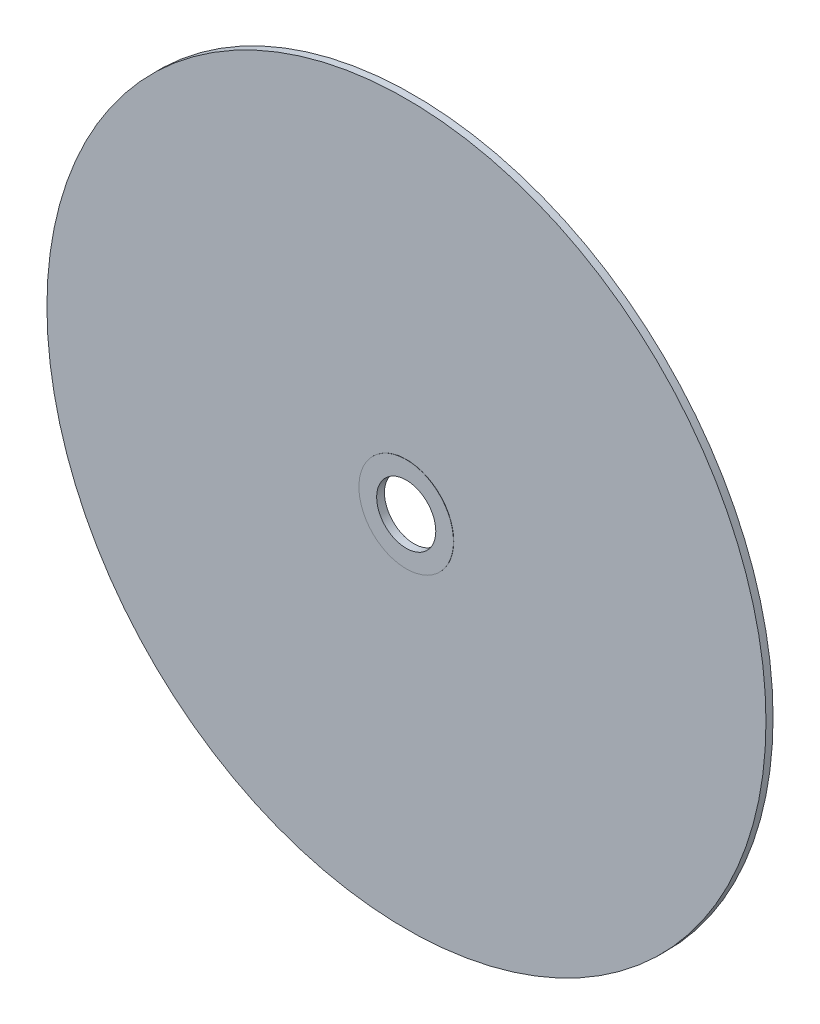
from build123d import *

# Parameters (mm, degrees)
SKETCH1_R                = 152
BOSS_EXTRUDE1_DEPTH      = 3
SKETCH2_R                = 12.5
CUT_EXTRUDE1_DEPTH       = 3
SKETCH3_R                = 20
BOSS_EXTRUDE2_DEPTH      = 0.1
BOSS_EXTRUDE2_DEPTH_BACK = 3.2
SKETCH4_R                = 12.5
CUT_EXTRUDE2_DEPTH       = 50.1


with BuildPart() as part:
    # Sketch1 → Boss-Extrude1 (new body)
    with BuildSketch(Plane.XY):
        Circle(SKETCH1_R)
    extrude(amount=BOSS_EXTRUDE1_DEPTH)

    # Sketch2 → Cut-Extrude1 (cut)
    with BuildSketch(Plane.XY.offset(3)):
        Circle(SKETCH2_R)
    extrude(amount=-CUT_EXTRUDE1_DEPTH, mode=Mode.SUBTRACT)

    # Sketch3 → Boss-Extrude2 (add, two sides)
    with BuildSketch(Plane.XY.offset(3)) as boss_extrude2_sk:
        Circle(SKETCH3_R)
    extrude(amount=BOSS_EXTRUDE2_DEPTH)
    extrude(boss_extrude2_sk.sketch, amount=-BOSS_EXTRUDE2_DEPTH_BACK)

    # Sketch4 → Cut-Extrude2 (cut)
    with BuildSketch(Plane(origin=(0, 0, -0.2), x_dir=(-1, 0, 0), z_dir=(0, 0, -1))):
        Circle(SKETCH4_R)
    extrude(amount=-CUT_EXTRUDE2_DEPTH, mode=Mode.SUBTRACT)


solid = part.part
